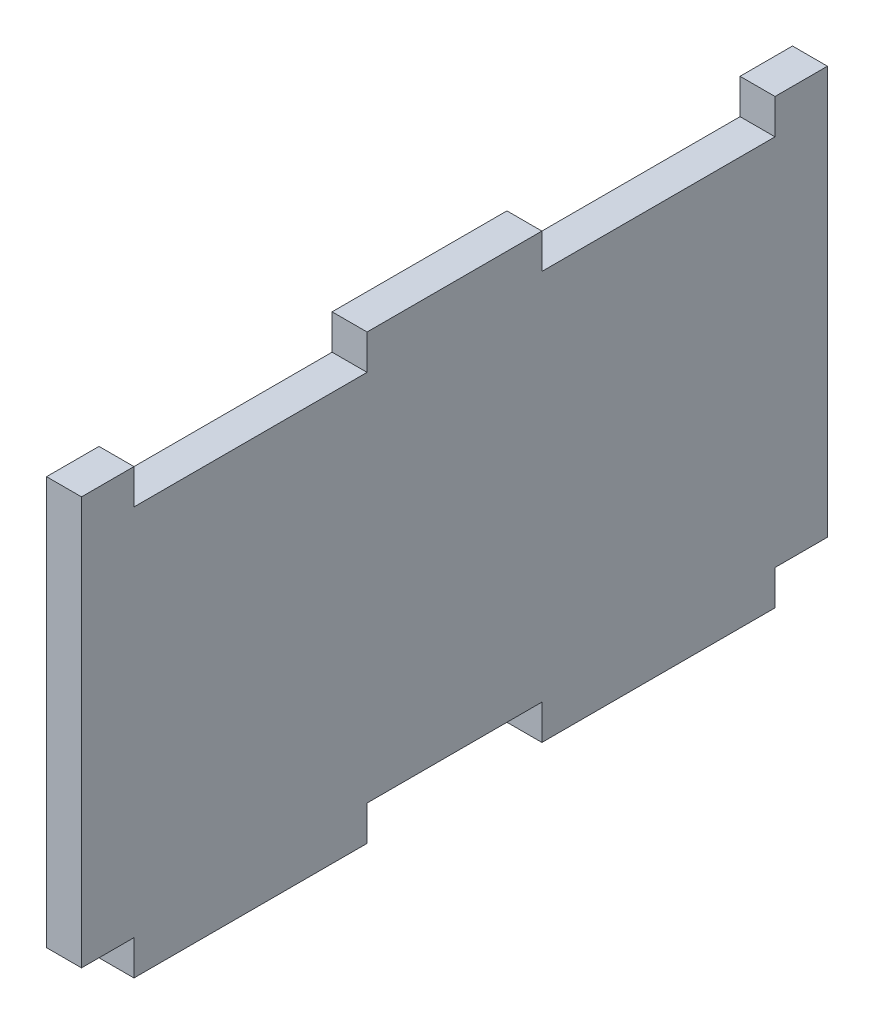
from build123d import *

# Parameters (mm, degrees)
BOSS_EXTRUDE1_DEPTH = 3
SKETCH2_W           = 213
SKETCH2_H           = 45
CUT_EXTRUDE1_DEPTH  = 10


with BuildPart() as part:
    # Sketch1 → Boss-Extrude1 (new body)
    with BuildSketch(Plane(origin=(0, 0, 0), x_dir=(0, 0, -1), z_dir=(1, 0, 0))):
        Polygon((24.5, 0), (39.5, 0), (39.5, -3), (59.5, -3), (59.5, 0), (74.5, 0), (74.5, -3), (94.5, -3), (94.5, 0), (109.5, 0), (109.5, -3), (129.5, -3), (129.5, 0), (144.5, 0), (144.5, -3), (164.5, -3), (164.5, 0), (179.5, 0), (179.5, -3), (199.5, -3), (199.5, 0), (214.5, 0), (214.5, -3), (234.5, -3), (234.5, 0), (249.5, 0), (249.5, -3), (269.5, -3), (269.5, 0), (277, 0), (277, 35), (269.5, 35), (269.5, 32), (249.5, 32), (249.5, 35), (234.5, 35), (234.5, 32), (214.5, 32), (214.5, 35), (199.5, 35), (199.5, 32), (179.5, 32), (179.5, 35), (164.5, 35), (164.5, 32), (144.5, 32), (144.5, 35), (129.5, 35), (129.5, 32), (109.5, 32), (109.5, 35), (94.5, 35), (94.5, 32), (74.5, 32), (74.5, 35), (59.5, 35), (59.5, 32), (39.5, 32), (39.5, 35), (24.5, 35), (24.5, 32), (4.5, 32), (4.5, 35), (0, 35), (0, 0), (4.5, 0), (4.5, -3), (24.5, -3), align=None)
    extrude(amount=BOSS_EXTRUDE1_DEPTH)

    # Sketch2 → Cut-Extrude1 (cut)
    with BuildSketch(Plane(origin=(3, 0, 0), x_dir=(0, 0, -1), z_dir=(1, 0, 0))):
        with Locations((170.5, 17.5)):
            Rectangle(SKETCH2_W, SKETCH2_H)
    extrude(amount=-CUT_EXTRUDE1_DEPTH, mode=Mode.SUBTRACT)


solid = part.part
